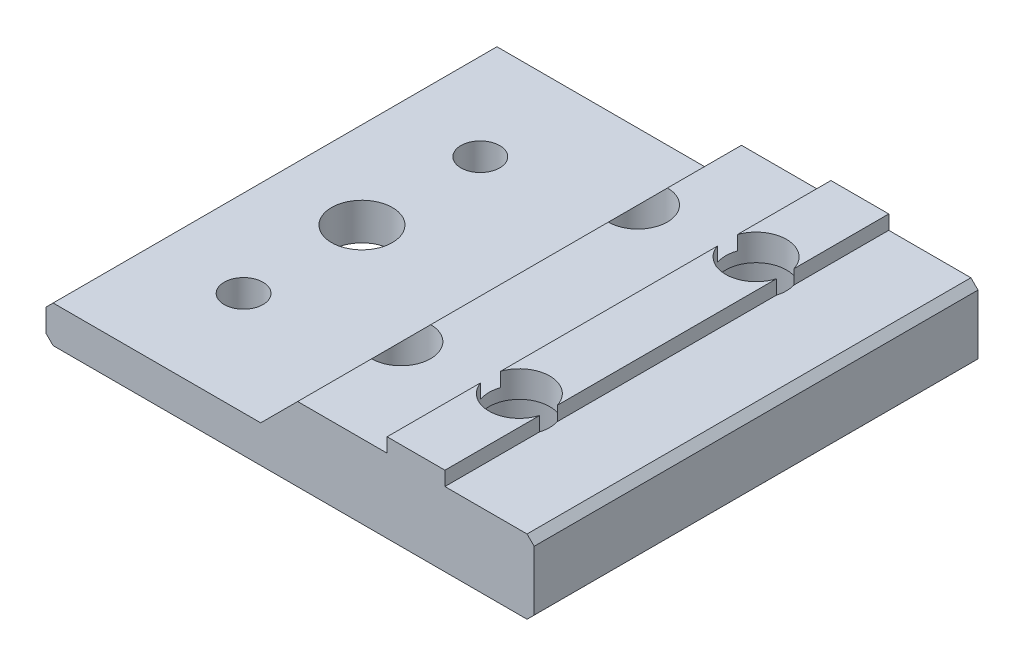
from build123d import *

# Parameters (mm, degrees)
EXTRUDE1_DEPTH     = 47.625
CUT_EXTRUDE1_DEPTH = 47.625
SKETCH3_R          = 5.1562
CUT_EXTRUDE2_DEPTH = 6.604
SKETCH4_R          = 3.175
CUT_EXTRUDE3_DEPTH = 10.4488
SKETCH5_R          = 2.0828
SKETCH5_R_2        = 3.2639
CUT_EXTRUDE4_DEPTH = 10.4488


with BuildPart() as part:
    # Sketch1 → Extrude1 (new body)
    with BuildSketch(Plane.XY):
        Polygon((55.524691805, 16.952365829), (55.524691805, 18.476365829), (61.730833978, 18.476365829), (61.729335279, 16.953119016), (70.543139545, 16.953119016), (71.305139176, 16.190369296), (71.305139176, 9.78956546), (70.543888896, 9.027565829), (19.685291805, 9.027565829), (18.923291805, 9.789565829), (18.923291805, 12.227965829), (19.685291805, 12.989965829), (41.961091805, 12.989965829), (45.923491805, 16.952365829), align=None)
    extrude(amount=EXTRUDE1_DEPTH)

    # Sketch2 → Cut-Extrude1 (cut)
    with BuildSketch(Plane.XZ.offset(-9.027565829)):
        with BuildLine():
            ThreePointArc((61.869039176, 36.5125), (60.913064999, 38.820425823), (58.605139176, 39.7764))
            Line((58.605139176, 39.7764), (58.605139176, 36.5125))
            Line((58.605139176, 36.5125), (61.869039176, 36.5125))
        make_face()
        with BuildLine():
            Line((58.605139176, 36.5125), (58.605139176, 39.7764))
            ThreePointArc((58.605139176, 39.7764), (56.297213353, 38.820425823), (55.341239176, 36.5125))
            Line((55.341239176, 36.5125), (58.605139176, 36.5125))
        make_face()
        with BuildLine():
            Line((61.869039176, 36.5125), (58.605139176, 36.5125))
            Line((58.605139176, 36.5125), (58.605139176, 33.2486))
            ThreePointArc((58.605139176, 33.2486), (60.913064999, 34.204574177), (61.869039176, 36.5125))
        make_face()
        with BuildLine():
            Line((58.605139176, 33.2486), (58.605139176, 36.5125))
            Line((58.605139176, 36.5125), (55.341239176, 36.5125))
            ThreePointArc((55.341239176, 36.5125), (56.297213353, 34.204574177), (58.605139176, 33.2486))
        make_face()
        with BuildLine():
            ThreePointArc((61.869039176, 11.1125), (60.913064999, 13.420425823), (58.605139176, 14.3764))
            Line((58.605139176, 14.3764), (58.605139176, 11.1125))
            Line((58.605139176, 11.1125), (61.869039176, 11.1125))
        make_face()
        with BuildLine():
            Line((58.605139176, 11.1125), (58.605139176, 14.3764))
            ThreePointArc((58.605139176, 14.3764), (56.297213353, 13.420425823), (55.341239176, 11.1125))
            Line((55.341239176, 11.1125), (58.605139176, 11.1125))
        make_face()
        with BuildLine():
            Line((61.869039176, 11.1125), (58.605139176, 11.1125))
            Line((58.605139176, 11.1125), (58.605139176, 7.8486))
            ThreePointArc((58.605139176, 7.8486), (60.913064999, 8.804574177), (61.869039176, 11.1125))
        make_face()
        with BuildLine():
            Line((58.605139176, 7.8486), (58.605139176, 11.1125))
            Line((58.605139176, 11.1125), (55.341239176, 11.1125))
            ThreePointArc((55.341239176, 11.1125), (56.297213353, 8.804574177), (58.605139176, 7.8486))
        make_face()
    extrude(amount=-CUT_EXTRUDE1_DEPTH, mode=Mode.SUBTRACT)

    # Sketch3 → Cut-Extrude2 (cut)
    with BuildSketch(Plane.XZ.offset(-9.027565829)):
        with Locations((58.605139176, 36.5125)):
            Circle(SKETCH3_R)
        with Locations((58.605139176, 11.1125)):
            Circle(SKETCH3_R)
    extrude(amount=-CUT_EXTRUDE2_DEPTH, mode=Mode.SUBTRACT)

    # Sketch4 → Cut-Extrude3 (cut, through all)
    with BuildSketch(Plane.XZ.offset(-9.027565829)):
        with Locations((45.905139176, 36.5125)):
            Circle(SKETCH4_R)
        with Locations((45.905139176, 11.1125)):
            Circle(SKETCH4_R)
    extrude(amount=-CUT_EXTRUDE3_DEPTH, mode=Mode.SUBTRACT)

    # Sketch5 → Cut-Extrude4 (cut, through all)
    with BuildSketch(Plane.XZ.offset(-9.027565829)):
        with Locations((29.014139176, 36.5125)):
            Circle(SKETCH5_R)
        with Locations((29.014139176, 11.1125)):
            Circle(SKETCH5_R)
        with Locations((29.014139176, 23.8125)):
            Circle(SKETCH5_R_2)
    extrude(amount=-CUT_EXTRUDE4_DEPTH, mode=Mode.SUBTRACT)


solid = part.part
